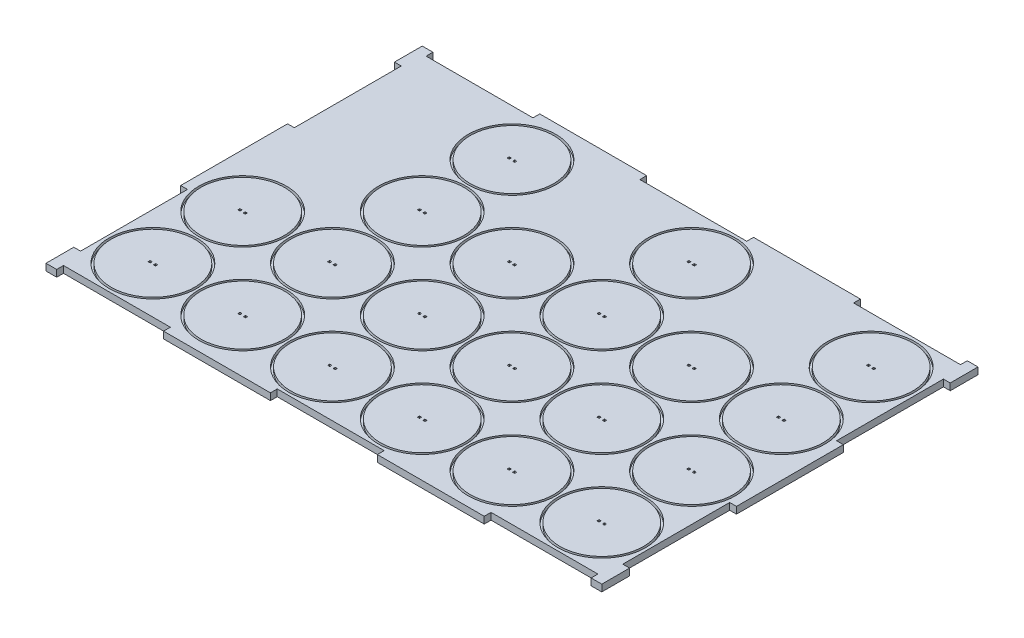
from build123d import *

# Parameters (mm, degrees)
SKETCH3_W                = 260
SKETCH3_H                = 176
BOSS_EXTRUDE2_DEPTH      = 1.5875
SKETCH4_R                = 20.5
SKETCH4_R_2              = 19.5
CUT_EXTRUDE1_DEPTH       = 1.5
SKETCH5_W                = 1
SKETCH5_H                = 1
CUT_EXTRUDE9_DEPTH       = 11.5
LPATTERN1_COUNT          = 4
LPATTERN1_PITCH          = 42
LPATTERN1_COUNT_DIR2     = 6
LPATTERN1_PITCH_DIR2     = 42
CUT_EXTRUDE10_DEPTH      = 158.016179501
CUT_EXTRUDE10_DEPTH_BACK = 11.5
SKETCH9_W                = 3.175
SKETCH9_H                = 50
SKETCH9_W_2              = 50
SKETCH9_H_2              = 3.18


with BuildPart() as part:
    # Sketch3 → Boss-Extrude2 (new, symmetric)
    with BuildSketch(Plane(origin=(0, 0, 0), x_dir=(1, 0, 0), z_dir=(0, 1, 0))):
        Rectangle(SKETCH3_W, SKETCH3_H)
    extrude(amount=BOSS_EXTRUDE2_DEPTH, both=True)

    # Sketch4 → Cut-Extrude1 (cut)
    # profile 1 of 20: a face of its own
    with BuildSketch(Plane(origin=(0, 1.5875, 0), x_dir=(1, 0, 0), z_dir=(0, 1, 0))):
        with Locations((63, -63)):
            Circle(SKETCH4_R)
        with Locations((63, -63)):
            Circle(SKETCH4_R_2, mode=Mode.SUBTRACT)
    # profile 2 of 20: a face of its own
    with BuildSketch(Plane(origin=(0, 1.5875, 0), x_dir=(1, 0, 0), z_dir=(0, 1, 0))):
        with Locations((105, -63)):
            Circle(SKETCH4_R)
        with Locations((105, -63)):
            Circle(SKETCH4_R_2, mode=Mode.SUBTRACT)
    # profile 3 of 20: a face of its own
    with BuildSketch(Plane(origin=(0, 1.5875, 0), x_dir=(1, 0, 0), z_dir=(0, 1, 0))):
        with Locations((21, -63)):
            Circle(SKETCH4_R)
        with Locations((21, -63)):
            Circle(SKETCH4_R_2, mode=Mode.SUBTRACT)
    # profile 4 of 20: a face of its own
    with BuildSketch(Plane(origin=(0, 1.5875, 0), x_dir=(1, 0, 0), z_dir=(0, 1, 0))):
        with Locations((-21, -63)):
            Circle(SKETCH4_R)
        with Locations((-21, -63)):
            Circle(SKETCH4_R_2, mode=Mode.SUBTRACT)
    # profile 5 of 20: a face of its own
    with BuildSketch(Plane(origin=(0, 1.5875, 0), x_dir=(1, 0, 0), z_dir=(0, 1, 0))):
        with Locations((-63, -63)):
            Circle(SKETCH4_R)
        with Locations((-63, -63)):
            Circle(SKETCH4_R_2, mode=Mode.SUBTRACT)
    # profile 6 of 20: a face of its own
    with BuildSketch(Plane(origin=(0, 1.5875, 0), x_dir=(1, 0, 0), z_dir=(0, 1, 0))):
        with Locations((-105, -63)):
            Circle(SKETCH4_R)
        with Locations((-105, -63)):
            Circle(SKETCH4_R_2, mode=Mode.SUBTRACT)
    # profile 7 of 20: a face of its own
    with BuildSketch(Plane(origin=(0, 1.5875, 0), x_dir=(1, 0, 0), z_dir=(0, 1, 0))):
        with Locations((63, -21)):
            Circle(SKETCH4_R)
        with Locations((63, -21)):
            Circle(SKETCH4_R_2, mode=Mode.SUBTRACT)
    # profile 8 of 20: a face of its own
    with BuildSketch(Plane(origin=(0, 1.5875, 0), x_dir=(1, 0, 0), z_dir=(0, 1, 0))):
        with Locations((21, -21)):
            Circle(SKETCH4_R)
        with Locations((21, -21)):
            Circle(SKETCH4_R_2, mode=Mode.SUBTRACT)
    # profile 9 of 20: a face of its own
    with BuildSketch(Plane(origin=(0, 1.5875, 0), x_dir=(1, 0, 0), z_dir=(0, 1, 0))):
        with Locations((-21, -21)):
            Circle(SKETCH4_R)
        with Locations((-21, -21)):
            Circle(SKETCH4_R_2, mode=Mode.SUBTRACT)
    # profile 10 of 20: a face of its own
    with BuildSketch(Plane(origin=(0, 1.5875, 0), x_dir=(1, 0, 0), z_dir=(0, 1, 0))):
        with Locations((-63, -21)):
            Circle(SKETCH4_R)
        with Locations((-63, -21)):
            Circle(SKETCH4_R_2, mode=Mode.SUBTRACT)
    # profile 11 of 20: a face of its own
    with BuildSketch(Plane(origin=(0, 1.5875, 0), x_dir=(1, 0, 0), z_dir=(0, 1, 0))):
        with Locations((-105, -21)):
            Circle(SKETCH4_R)
        with Locations((-105, -21)):
            Circle(SKETCH4_R_2, mode=Mode.SUBTRACT)
    # profile 12 of 20: a face of its own
    with BuildSketch(Plane(origin=(0, 1.5875, 0), x_dir=(1, 0, 0), z_dir=(0, 1, 0))):
        with Locations((63, 21)):
            Circle(SKETCH4_R)
        with Locations((63, 21)):
            Circle(SKETCH4_R_2, mode=Mode.SUBTRACT)
    # profile 13 of 20: a face of its own
    with BuildSketch(Plane(origin=(0, 1.5875, 0), x_dir=(1, 0, 0), z_dir=(0, 1, 0))):
        with Locations((21, 21)):
            Circle(SKETCH4_R)
        with Locations((21, 21)):
            Circle(SKETCH4_R_2, mode=Mode.SUBTRACT)
    # profile 14 of 20: a face of its own
    with BuildSketch(Plane(origin=(0, 1.5875, 0), x_dir=(1, 0, 0), z_dir=(0, 1, 0))):
        with Locations((-21, 21)):
            Circle(SKETCH4_R)
        with Locations((-21, 21)):
            Circle(SKETCH4_R_2, mode=Mode.SUBTRACT)
    # profile 15 of 20: a face of its own
    with BuildSketch(Plane(origin=(0, 1.5875, 0), x_dir=(1, 0, 0), z_dir=(0, 1, 0))):
        with Locations((-63, 21)):
            Circle(SKETCH4_R)
        with Locations((-63, 21)):
            Circle(SKETCH4_R_2, mode=Mode.SUBTRACT)
    # profile 16 of 20: a face of its own
    with BuildSketch(Plane(origin=(0, 1.5875, 0), x_dir=(1, 0, 0), z_dir=(0, 1, 0))):
        with Locations((21, 63)):
            Circle(SKETCH4_R)
        with Locations((21, 63)):
            Circle(SKETCH4_R_2, mode=Mode.SUBTRACT)
    # profile 17 of 20: a face of its own
    with BuildSketch(Plane(origin=(0, 1.5875, 0), x_dir=(1, 0, 0), z_dir=(0, 1, 0))):
        with Locations((-63, 63)):
            Circle(SKETCH4_R)
        with Locations((-63, 63)):
            Circle(SKETCH4_R_2, mode=Mode.SUBTRACT)
    # profile 18 of 20: a face of its own
    with BuildSketch(Plane(origin=(0, 1.5875, 0), x_dir=(1, 0, 0), z_dir=(0, 1, 0))):
        with Locations((105, -21)):
            Circle(SKETCH4_R)
        with Locations((105, -21)):
            Circle(SKETCH4_R_2, mode=Mode.SUBTRACT)
    # profile 19 of 20: a face of its own
    with BuildSketch(Plane(origin=(0, 1.5875, 0), x_dir=(1, 0, 0), z_dir=(0, 1, 0))):
        with Locations((105, 21)):
            Circle(SKETCH4_R)
        with Locations((105, 21)):
            Circle(SKETCH4_R_2, mode=Mode.SUBTRACT)
    # profile 20 of 20: a face of its own
    with BuildSketch(Plane(origin=(0, 1.5875, 0), x_dir=(1, 0, 0), z_dir=(0, 1, 0))):
        with Locations((105, 63)):
            Circle(SKETCH4_R)
        with Locations((105, 63)):
            Circle(SKETCH4_R_2, mode=Mode.SUBTRACT)
    extrude(amount=-CUT_EXTRUDE1_DEPTH, mode=Mode.SUBTRACT)

    # Sketch5 → Cut-Extrude9 (cut, symmetric)
    with BuildSketch(Plane(origin=(0, 1.5875, 0), x_dir=(1, 0, 0), z_dir=(0, 1, 0))):
        with Locations((103.73, -63)):
            Rectangle(SKETCH5_W, SKETCH5_H)
        with Locations((106.27, -63)):
            Rectangle(SKETCH5_W, SKETCH5_H)
    cut_extrude9 = extrude(amount=CUT_EXTRUDE9_DEPTH, both=True, mode=Mode.SUBTRACT)

    # LPattern1: Cut-Extrude9 4 × 6, 4 skipped
    with Locations(*[(-j * LPATTERN1_PITCH_DIR2, 0, -i * LPATTERN1_PITCH) for i in range(LPATTERN1_COUNT) for j in range(LPATTERN1_COUNT_DIR2) if (i, j) not in ((0, 0), (2, 5), (3, 1), (3, 3), (3, 5))]):
        add(cut_extrude9, mode=Mode.SUBTRACT)

    # Sketch9 → Cut-Extrude10 (cut, two sides: drawn at the far end of the back side and taken through both)
    with BuildSketch(Plane(origin=(0, 1.5875, 0), x_dir=(1, 0, 0), z_dir=(0, 1, 0)).offset(-CUT_EXTRUDE10_DEPTH_BACK)):
        with Locations((-128.4125, 50)):
            Rectangle(SKETCH9_W, SKETCH9_H)
        with Locations((-128.4125, -50)):
            Rectangle(SKETCH9_W, SKETCH9_H)
        with Locations((-100, 86.41)):
            Rectangle(SKETCH9_W_2, SKETCH9_H_2)
        with Locations((0, 86.41)):
            Rectangle(SKETCH9_W_2, SKETCH9_H_2)
        with Locations((-100, -86.41)):
            Rectangle(SKETCH9_W_2, SKETCH9_H_2)
        with Locations((100, 86.41)):
            Rectangle(SKETCH9_W_2, SKETCH9_H_2)
        with Locations((0, -86.41)):
            Rectangle(SKETCH9_W_2, SKETCH9_H_2)
        with Locations((100, -86.41)):
            Rectangle(SKETCH9_W_2, SKETCH9_H_2)
        with Locations((128.4125, 50)):
            Rectangle(SKETCH9_W, SKETCH9_H)
        with Locations((128.4125, -50)):
            Rectangle(SKETCH9_W, SKETCH9_H)
    extrude(amount=CUT_EXTRUDE10_DEPTH + CUT_EXTRUDE10_DEPTH_BACK, mode=Mode.SUBTRACT)


solid = part.part
